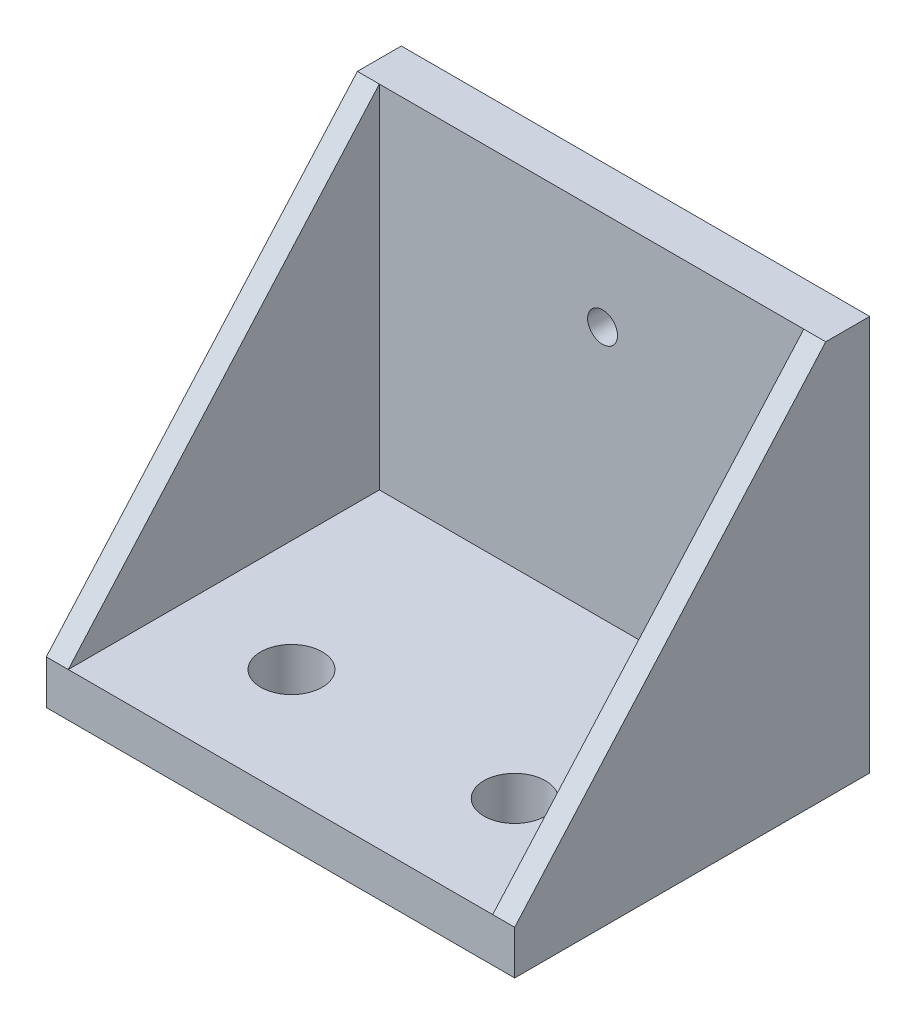
from build123d import *

# Parameters (mm, degrees)
SKETCH1_W           = 50.8
SKETCH1_H           = 35.4
SKETCH1_R           = 3.5
BOSS_EXTRUDE1_DEPTH = 5
SKETCH2_W           = 50.8
SKETCH2_H           = 45
BOSS_EXTRUDE2_DEPTH = 5
SKETCH3_R           = 1.7
CUT_EXTRUDE1_DEPTH  = 5
BOSS_EXTRUDE3_DEPTH = 2.5
BOSS_EXTRUDE4_DEPTH = 2.5


with BuildPart() as part:
    # Sketch1 → Boss-Extrude1 (new body)
    with BuildSketch(Plane(origin=(0, 0, 0), x_dir=(1, 0, 0), z_dir=(0, 1, 0))):
        with Locations((-25.4, 17.7)):
            Rectangle(SKETCH1_W, SKETCH1_H)
        with Locations((-38.1, 12.7)):
            Circle(SKETCH1_R, mode=Mode.SUBTRACT)
        with Locations((-12.7, 12.7)):
            Circle(SKETCH1_R, mode=Mode.SUBTRACT)
    extrude(amount=BOSS_EXTRUDE1_DEPTH)

    # Sketch2 → Boss-Extrude2 (add)
    with BuildSketch(Plane(origin=(0, 0, -35.4), x_dir=(-1, 0, 0), z_dir=(0, 0, -1))):
        with Locations((25.4, 22.5)):
            Rectangle(SKETCH2_W, SKETCH2_H)
    extrude(amount=BOSS_EXTRUDE2_DEPTH)

    # Sketch3 → Cut-Extrude1 (cut)
    with BuildSketch(Plane(origin=(0, 0, -40.4), x_dir=(-1, 0, 0), z_dir=(0, 0, -1))):
        with Locations((25.4, 33.75)):
            Circle(SKETCH3_R)
    extrude(amount=-CUT_EXTRUDE1_DEPTH, mode=Mode.SUBTRACT)

    # Sketch4 → Boss-Extrude3 (add)
    with BuildSketch(Plane(origin=(0, 0, 0), x_dir=(0, 0, -1), z_dir=(1, 0, 0))):
        Polygon((0, 5), (35.4, 45), (40.4, 45), (40.4, 0), (0, 0), align=None)
    extrude(amount=-BOSS_EXTRUDE3_DEPTH)

    # Sketch5 → Boss-Extrude4 (add)
    with BuildSketch(Plane.ZY.offset(50.8)):
        Polygon((-35.4, 45), (-40.4, 45), (-40.4, 0), (0, 0), (0, 5), align=None)
    extrude(amount=BOSS_EXTRUDE4_DEPTH)


solid = part.part
